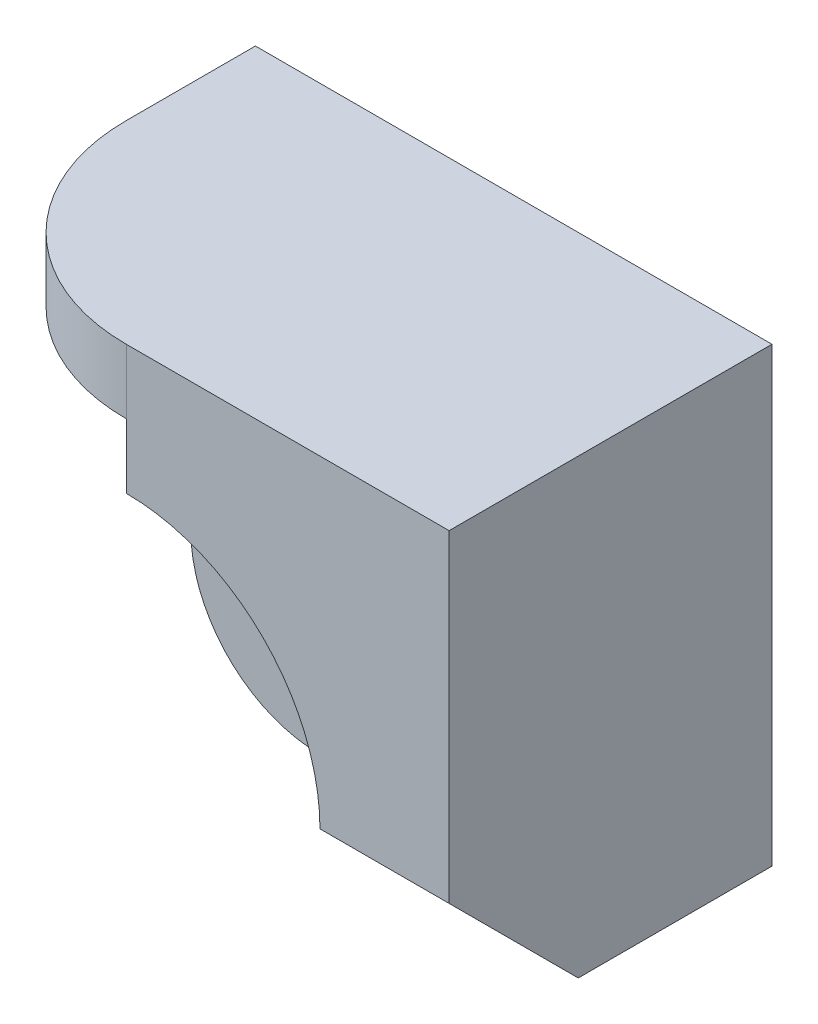
from build123d import *

# Parameters (mm, degrees)
SKETCH1_R           = 1
BOSS_EXTRUDE1_DEPTH = 5
SKETCH2_OUTSIDE_W   = 12.35
SKETCH2_OUTSIDE_H   = 11.35
CUT_EXTRUDE1_DEPTH  = 3
CUT_EXTRUDE2_DEPTH  = 3
CUT_EXTRUDE3_DEPTH  = 3


with BuildPart() as part:
    # Sketch1 → Boss-Extrude1 (new body)
    with BuildSketch(Plane.XY):
        with BuildLine():
            Line((-2, 0), (-2, 4))
            Line((-2, 4), (-3, 4))
            Line((-3, 4), (-3, 5))
            Line((-3, 5), (5, 5))
            Line((5, 5), (5, -2))
            Line((5, -2), (0, -2))
            ThreePointArc((0, -2), (-1.414213562, -1.414213562), (-2, 0))
        make_face()
        Circle(SKETCH1_R, mode=Mode.SUBTRACT)
    extrude(amount=BOSS_EXTRUDE1_DEPTH)

    # Sketch2 outside → Cut-Extrude1 (cut)
    with BuildSketch(Plane.XY.offset(5)):
        with Locations((1, 1.5)):
            Rectangle(SKETCH2_OUTSIDE_W, SKETCH2_OUTSIDE_H)
        with BuildLine():
            Line((5, -2), (5, 5))
            Line((5, 5), (-3, 5))
            Line((-3, 5), (-3, 4))
            Line((-3, 4), (-2, 4))
            Line((-2, 4), (0, 4))
            Line((0, 4), (0, 3))
            ThreePointArc((0, 3), (2.121320344, 2.121320344), (3, 0))
            Line((3, 0), (3, -2))
            Line((3, -2), (5, -2))
        make_face(mode=Mode.SUBTRACT)
    extrude(amount=-CUT_EXTRUDE1_DEPTH, mode=Mode.SUBTRACT)

    # Sketch3 → Cut-Extrude2 (cut)
    with BuildSketch(Plane.XZ.offset(-4)):
        with BuildLine():
            Line((-3, 2), (-3, 5))
            Line((-3, 5), (0, 5))
            ThreePointArc((0, 5), (-2.121320344, 4.121320344), (-3, 2))
        make_face()
    extrude(amount=-CUT_EXTRUDE2_DEPTH, mode=Mode.SUBTRACT)

    # Sketch4 → Cut-Extrude3 (cut, through all)
    with BuildSketch(Plane.ZY.offset(-3)):
        Polygon((5, 0), (3, -2), (5, -2), align=None)
    extrude(amount=-CUT_EXTRUDE3_DEPTH, mode=Mode.SUBTRACT)


solid = part.part
